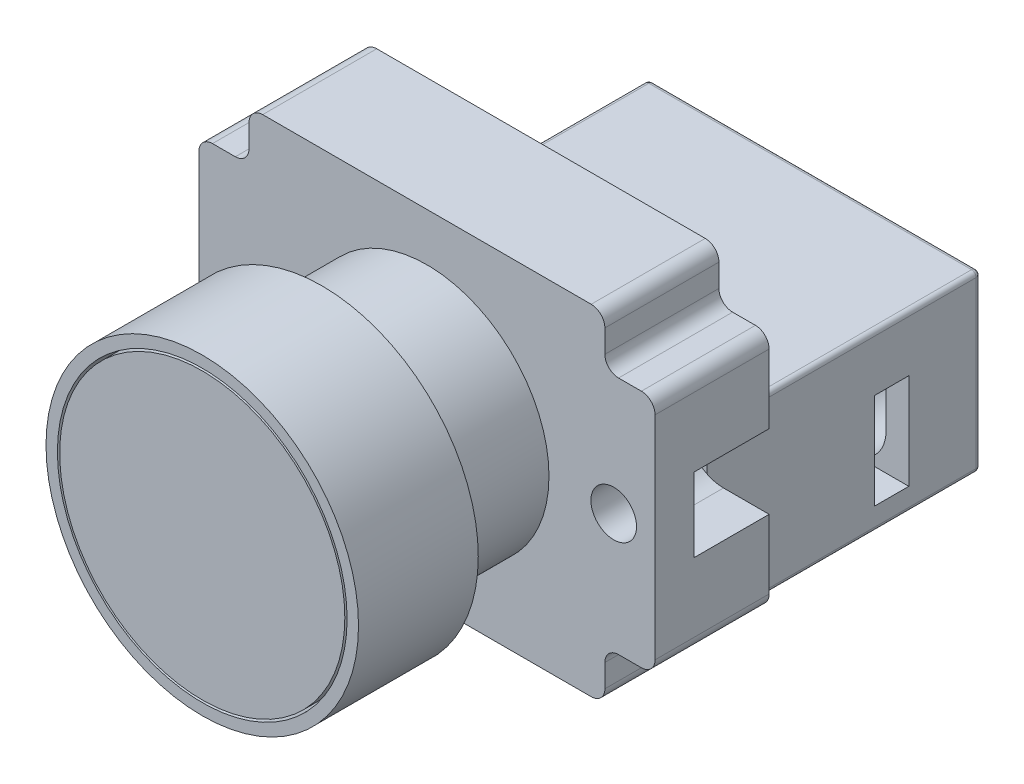
from build123d import *

# Parameters (mm, degrees)
SKETCH1_R           = 10.7
BOSS_EXTRUDE1_DEPTH = 4.6
BOSS_EXTRUDE2_START = 4.6
SKETCH2_R           = 13.7
SKETCH2_R_2         = 12.7
BOSS_EXTRUDE2_DEPTH = 10.5
BOSS_EXTRUDE3_START = 4.6
SKETCH3_R           = 12.5
BOSS_EXTRUDE3_DEPTH = 10.5
BOSS_EXTRUDE4_START = -4.6
BOSS_EXTRUDE4_DEPTH = 10
FILLET1_R           = 1.2
CUT_EXTRUDE1_START  = -14.6
SKETCH5_W           = 4
SKETCH5_H           = 6.5
CUT_EXTRUDE1_DEPTH  = 6.6
CUT_EXTRUDE2_START  = -8
SKETCH6_R           = 2
CUT_EXTRUDE2_DEPTH  = 12.6
BOSS_EXTRUDE5_START = -14.6
SKETCH7_W           = 29.1
SKETCH7_H           = 15.3
BOSS_EXTRUDE5_DEPTH = 24
FILLET2_R           = 0.4
CUT_EXTRUDE3_START  = -14.6
SKETCH8_R           = 10.9
CUT_EXTRUDE3_DEPTH  = 4.8
CUT_EXTRUDE4_START  = -38.6
SKETCH9_W           = 6.4
SKETCH9_H           = 3.9
CUT_EXTRUDE4_DEPTH  = 9
CUT_EXTRUDE5_START  = -14.55
SKETCH10_W          = 3
SKETCH10_H          = 8.4
CUT_EXTRUDE5_DEPTH  = 11
CUT_EXTRUDE6_START  = 14.55
SKETCH11_W          = 3
SKETCH11_H          = 8.4
CUT_EXTRUDE6_DEPTH  = 11


with BuildPart() as part:
    # Sketch1 → Boss-Extrude1 (new body, symmetric)
    with BuildSketch(Plane.XY):
        Circle(SKETCH1_R)
    extrude(amount=BOSS_EXTRUDE1_DEPTH, both=True)

    # Sketch3 → Boss-Extrude3 (add)
    with BuildSketch(Plane.XY.offset(BOSS_EXTRUDE3_START)):
        Circle(SKETCH3_R)
    extrude(amount=BOSS_EXTRUDE3_DEPTH)

    # Sketch4 → Boss-Extrude4 (add)
    with BuildSketch(Plane.XY.offset(BOSS_EXTRUDE4_START)):
        Polygon((-15.6, -10.5), (-15.6, -14.9), (15.6, -14.9), (15.6, -10.5), (20, -10.5), (20, 10.5), (15.6, 10.5), (15.6, 14.9), (-15.6, 14.9), (-15.6, 10.5), (-20, 10.5), (-20, -10.5), align=None)
    extrude(amount=-BOSS_EXTRUDE4_DEPTH)

    # Fillet1
    fillet1_edges = [part.edges().sort_by_distance(p)[0] for p in [
        (15.6, 10.5, -9.6),
        (20, 10.5, -9.6),
        (20, -10.5, -9.6),
        (15.6, -10.5, -9.6),
        (15.6, -14.9, -9.6),
        (-15.6, -14.9, -9.6),
        (-15.6, -10.5, -9.6),
        (-20, -10.5, -9.6),
        (-20, 10.5, -9.6),
        (-15.6, 10.5, -9.6),
        (-15.6, 14.9, -9.6),
        (15.6, 14.9, -9.6),
    ]]
    fillet(fillet1_edges, radius=FILLET1_R)

    # Sketch5 → Cut-Extrude1 (cut)
    with BuildSketch(Plane.XY.offset(CUT_EXTRUDE1_START)):
        with Locations((18, 0)):
            Rectangle(SKETCH5_W, SKETCH5_H)
        with BuildLine():
            Line((16, 3.25), (16, -3.25))
            ThreePointArc((16, -3.25), (12.75, 0), (16, 3.25))
        make_face()
        with BuildLine():
            ThreePointArc((-16, 3.25), (-12.75, 0), (-16, -3.25))
            Line((-16, -3.25), (-16, 3.25))
        make_face()
        with Locations((-18, 0)):
            Rectangle(SKETCH5_W, SKETCH5_H)
    extrude(amount=CUT_EXTRUDE1_DEPTH, mode=Mode.SUBTRACT)

    # Sketch6 → Cut-Extrude2 (cut)
    with BuildSketch(Plane.XY.offset(CUT_EXTRUDE2_START)):
        with Locations((16.375, 0)):
            Circle(SKETCH6_R)
        with Locations((-16.375, 0)):
            Circle(SKETCH6_R)
    extrude(amount=CUT_EXTRUDE2_DEPTH, mode=Mode.SUBTRACT)

    # Sketch7 → Boss-Extrude5 (add)
    with BuildSketch(Plane.XY.offset(BOSS_EXTRUDE5_START)):
        with Locations((0, -7.05)):
            Rectangle(SKETCH7_W, SKETCH7_H)
    extrude(amount=-BOSS_EXTRUDE5_DEPTH)

    # Fillet2
    fillet2_edges = [part.edges().sort_by_distance(p)[0] for p in [
        (0, -14.7, -38.6),
        (14.55, -14.7, -26.6),
        (-14.55, -7.05, -38.6),
        (-14.55, -14.7, -26.6),
        (0, 0.6, -38.6),
        (-14.55, 0.6, -26.6),
        (14.55, -7.05, -38.6),
        (14.55, 0.6, -26.6),
    ]]
    fillet(fillet2_edges, radius=FILLET2_R)

    # Sketch8 → Cut-Extrude3 (cut)
    with BuildSketch(Plane.XY.offset(CUT_EXTRUDE3_START)):
        Circle(SKETCH8_R)
    extrude(amount=CUT_EXTRUDE3_DEPTH, mode=Mode.SUBTRACT)

    # Sketch9 → Cut-Extrude4 (cut)
    with BuildSketch(Plane.XY.offset(CUT_EXTRUDE4_START)):
        with Locations((9.35, -7.55)):
            Rectangle(SKETCH9_W, SKETCH9_H)
        with BuildLine():
            ThreePointArc((12.55, -9.5), (9.35, -12.7), (6.15, -9.5))
            Line((6.15, -9.5), (12.55, -9.5))
        make_face()
        with Locations((-9.35, -7.55)):
            Rectangle(SKETCH9_W, SKETCH9_H)
        with BuildLine():
            ThreePointArc((-6.15, -9.5), (-9.35, -12.7), (-12.55, -9.5))
            Line((-12.55, -9.5), (-6.15, -9.5))
        make_face()
    extrude(amount=CUT_EXTRUDE4_DEPTH, mode=Mode.SUBTRACT)

    # Sketch10 → Cut-Extrude5 (cut)
    with BuildSketch(Plane(origin=(0, 0, 0), x_dir=(0, 0, -1), z_dir=(1, 0, 0)).offset(CUT_EXTRUDE5_START)):
        with Locations((30.8, -8.5)):
            Rectangle(SKETCH10_W, SKETCH10_H)
    extrude(amount=CUT_EXTRUDE5_DEPTH, mode=Mode.SUBTRACT)

    # Sketch11 → Cut-Extrude6 (cut)
    with BuildSketch(Plane(origin=(0, 0, 0), x_dir=(0, 0, -1), z_dir=(1, 0, 0)).offset(CUT_EXTRUDE6_START)):
        with Locations((30.8, -8.5)):
            Rectangle(SKETCH11_W, SKETCH11_H)
    extrude(amount=-CUT_EXTRUDE6_DEPTH, mode=Mode.SUBTRACT)


with BuildPart() as body_2:
    # Sketch2 → Boss-Extrude2 (new body)
    with BuildSketch(Plane.XY.offset(BOSS_EXTRUDE2_START)):
        Circle(SKETCH2_R)
        Circle(SKETCH2_R_2, mode=Mode.SUBTRACT)
    extrude(amount=BOSS_EXTRUDE2_DEPTH)


solid = Compound([part.part, body_2.part])
